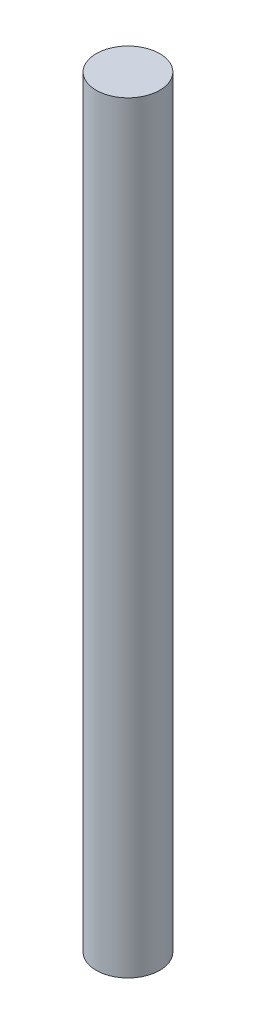
from build123d import *

# Parameters (mm, degrees)
SKETCH1_R           = 1.5
BOSS_EXTRUDE1_DEPTH = 36


with BuildPart() as part:
    # Sketch1 → Boss-Extrude1 (new body)
    with BuildSketch(Plane(origin=(0, 0, 0), x_dir=(1, 0, 0), z_dir=(0, 1, 0))):
        Circle(SKETCH1_R)
    extrude(amount=BOSS_EXTRUDE1_DEPTH)


solid = part.part
